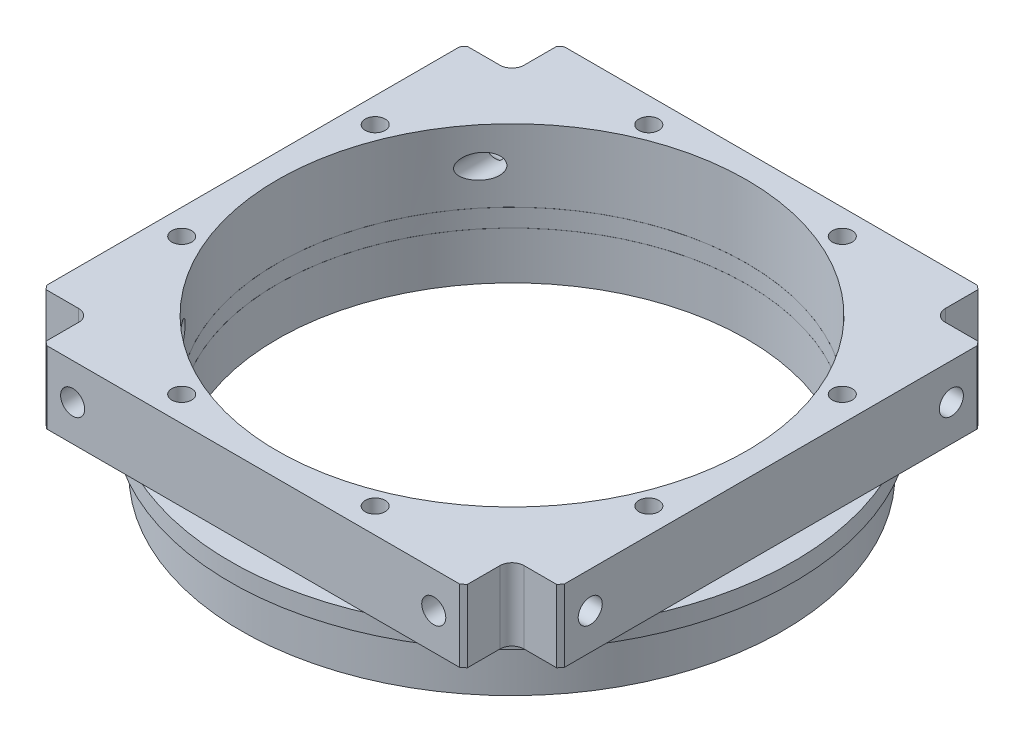
from build123d import *

# Parameters (mm, degrees)
SKETCH_2_OUTSIDE_W          = 143.448
SKETCH_2_OUTSIDE_H          = 143.448
SKETCH_2_OUTSIDE_W_2        = 86
SKETCH_2_OUTSIDE_H_2        = 86
CUT_EXTRUDE_1_DEPTH         = 12
SKETCH_4_R                  = 2
CUT_EXTRUDE_3_DEPTH         = 90.8
SKETCH_5_R                  = 2
CUT_EXTRUDE_4_DEPTH         = 12
CUT_EXTRUDE_START           = -86
SKETCH_5_2_R                = 2
CUT_EXTRUDE_5_DEPTH         = 12
SKETCH_6_R                  = 1.65
CUT_EXTRUDE_6_DEPTH         = 100
SKETCH_10_R                 = 2.1
CUT_EXTRUDE_8_DEPTH         = 10.9
PATTERN_CIRCULAR_1_COUNT    = 8
CUT_EXTRUDE_7_DEPTH         = 20
SKETCH_11_W                 = 136.197392648
SKETCH_11_H                 = 0.01
CUT_EXTRUDE_3326_DEPTH      = 47.8
CUT_EXTRUDE_3326_DEPTH_BACK = 47.8


with BuildPart() as part:
    # 草图1 → 旋转1 (revolve)
    with BuildSketch(Plane.XY):
        Polygon((-39, 0), (-45, 0), (-45, 7.9), (-46.8, 7.9), (-46.8, 10.9), (-55, 10.9), (-55, 22.9), (-39, 22.9), align=None)
    revolve(axis=Axis((0, 0, 0), (0, 1, 0)))

    # 草图2 outside → 切除-拉伸1 (cut)
    with BuildSketch(Plane(origin=(0, 22.9, 0), x_dir=(1, 0, 0), z_dir=(0, 1, 0))):
        Rectangle(SKETCH_2_OUTSIDE_W, SKETCH_2_OUTSIDE_H)
        Rectangle(SKETCH_2_OUTSIDE_W_2, SKETCH_2_OUTSIDE_H_2, mode=Mode.SUBTRACT)
    extrude(amount=-CUT_EXTRUDE_1_DEPTH, mode=Mode.SUBTRACT)

    # 草图4 → 切除-拉伸3 (cut, through all)
    with BuildSketch(Plane.XY.offset(43)):
        with Locations((-30, 16.9)):
            Circle(SKETCH_4_R)
        with Locations((30, 16.9)):
            Circle(SKETCH_4_R)
    extrude(amount=-CUT_EXTRUDE_3_DEPTH, mode=Mode.SUBTRACT)

    # 草图5 → 切除-拉伸4 (cut)
    with BuildSketch(Plane.ZY.offset(43)):
        with Locations((-30, 16.9)):
            Circle(SKETCH_5_R)
        with Locations((30, 16.9)):
            Circle(SKETCH_5_R)
    extrude(amount=-CUT_EXTRUDE_4_DEPTH, mode=Mode.SUBTRACT)

    # 草图5<2> → 切除-拉伸5 (cut)
    with BuildSketch(Plane.ZY.offset(43).offset(CUT_EXTRUDE_START)):
        with Locations((-30, 16.9)):
            Circle(SKETCH_5_2_R)
        with Locations((30, 16.9)):
            Circle(SKETCH_5_2_R)
    extrude(amount=CUT_EXTRUDE_5_DEPTH, mode=Mode.SUBTRACT)

    # 草图6 → 切除-拉伸6 (cut)
    with BuildSketch(Plane.XZ):
        with Locations((-16.072704159, -38.802940365)):
            Circle(SKETCH_6_R)
    cut_extrude_6 = extrude(amount=-CUT_EXTRUDE_6_DEPTH, mode=Mode.SUBTRACT)

    # 草图10 → 切除-拉伸8 (cut)
    with BuildSketch(Plane.XZ):
        with Locations((-16.072704159, -38.802940365)):
            Circle(SKETCH_10_R)
    cut_extrude_8 = extrude(amount=-CUT_EXTRUDE_8_DEPTH, mode=Mode.SUBTRACT)

    # 阵列(圆周)1: 切除-拉伸6, 切除-拉伸8 ×8 about axis
    pattern_circular_1_axis = Axis((0, 0, 0), (0, 1, 0))
    for i in range(1, PATTERN_CIRCULAR_1_COUNT):
        add(cut_extrude_6.rotate(pattern_circular_1_axis, i * 360 / PATTERN_CIRCULAR_1_COUNT), mode=Mode.SUBTRACT)
        add(cut_extrude_8.rotate(pattern_circular_1_axis, i * 360 / PATTERN_CIRCULAR_1_COUNT), mode=Mode.SUBTRACT)

    # 草图7 → 切除-拉伸7 (cut)
    with BuildSketch(Plane(origin=(0, 22.9, 0), x_dir=(1, 0, 0), z_dir=(0, 1, 0))):
        with BuildLine():
            Line((-37, 35), (-53, 35))
            ThreePointArc((-53, 35), (-54.414213562, 35.585786438), (-55, 37))
            Line((-55, 37), (-55, 53))
            ThreePointArc((-55, 53), (-54.414213562, 54.414213562), (-53, 55))
            Line((-53, 55), (-37, 55))
            ThreePointArc((-37, 55), (-35.585786438, 54.414213562), (-35, 53))
            Line((-35, 53), (-35, 37))
            ThreePointArc((-35, 37), (-35.585786438, 35.585786438), (-37, 35))
        make_face()
        with BuildLine():
            Line((37, 35), (53, 35))
            ThreePointArc((53, 35), (54.414213562, 35.585786438), (55, 37))
            Line((55, 37), (55, 53))
            ThreePointArc((55, 53), (54.414213562, 54.414213562), (53, 55))
            Line((53, 55), (37, 55))
            ThreePointArc((37, 55), (35.585786438, 54.414213562), (35, 53))
            Line((35, 53), (35, 37))
            ThreePointArc((35, 37), (35.585786438, 35.585786438), (37, 35))
        make_face()
        with BuildLine():
            Line((37, -35), (53, -35))
            ThreePointArc((53, -35), (54.414213562, -35.585786438), (55, -37))
            Line((55, -37), (55, -53))
            ThreePointArc((55, -53), (54.414213562, -54.414213562), (53, -55))
            Line((53, -55), (37, -55))
            ThreePointArc((37, -55), (35.585786438, -54.414213562), (35, -53))
            Line((35, -53), (35, -37))
            ThreePointArc((35, -37), (35.585786438, -35.585786438), (37, -35))
        make_face()
        with BuildLine():
            Line((-37, -35), (-53, -35))
            ThreePointArc((-53, -35), (-54.414213562, -35.585786438), (-55, -37))
            Line((-55, -37), (-55, -53))
            ThreePointArc((-55, -53), (-54.414213562, -54.414213562), (-53, -55))
            Line((-53, -55), (-37, -55))
            ThreePointArc((-37, -55), (-35.585786438, -54.414213562), (-35, -53))
            Line((-35, -53), (-35, -37))
            ThreePointArc((-35, -37), (-35.585786438, -35.585786438), (-37, -35))
        make_face()
    extrude(amount=-CUT_EXTRUDE_7_DEPTH, mode=Mode.SUBTRACT)

    # 草图11 → Cut-Extrude 3326 (cut, two sides)
    with BuildSketch(Plane(origin=(0, 0, 0), x_dir=(0, 0, -1), z_dir=(1, 0, 0))) as cut_extrude_3326_sk:
        with Locations((-5.996836933, 7.895)):
            Rectangle(SKETCH_11_W, SKETCH_11_H)
        with Locations((-5.996836933, 10.895)):
            Rectangle(SKETCH_11_W, SKETCH_11_H)
    extrude(amount=CUT_EXTRUDE_3326_DEPTH, mode=Mode.SUBTRACT)
    extrude(cut_extrude_3326_sk.sketch, amount=-CUT_EXTRUDE_3326_DEPTH_BACK, mode=Mode.SUBTRACT)


solid = part.part
